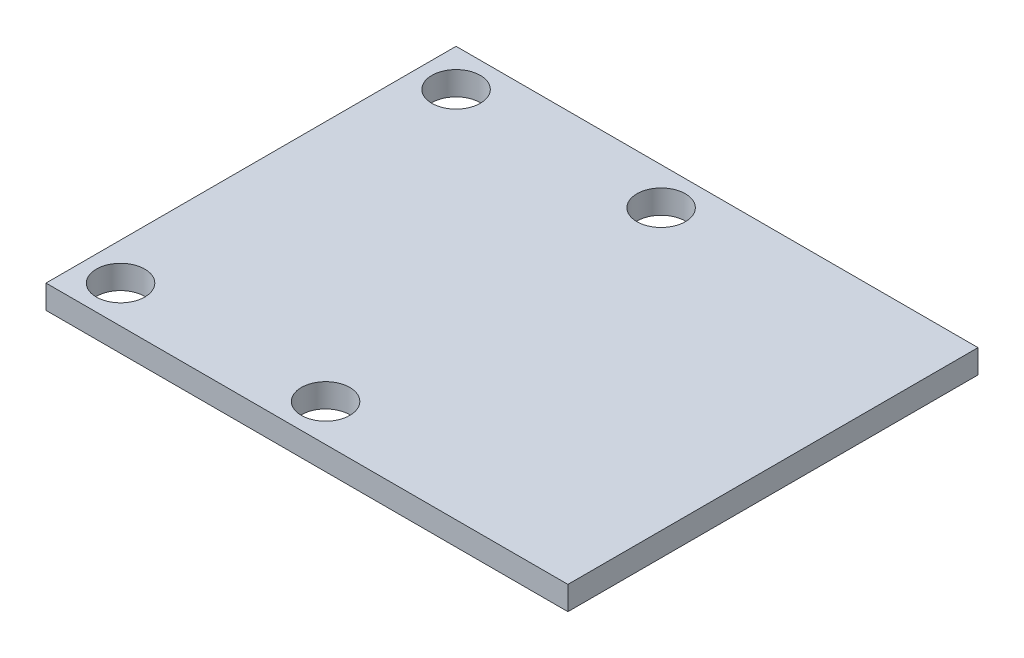
from build123d import *

# Parameters (mm, degrees)
SKETCH1_W            = 28
SKETCH1_H            = 22
BOSS_EXTRUDE1_DEPTH  = 1.27
SKETCH2_R            = 1.2999974
CUT_EXTRUDE2_DEPTH   = 2.27
LPATTERN1_COUNT      = 2
LPATTERN1_PITCH      = 11
LPATTERN1_COUNT_DIR2 = 2
LPATTERN1_PITCH_DIR2 = 18


with BuildPart() as part:
    # Sketch1 → Boss-Extrude1 (new body)
    with BuildSketch(Plane(origin=(0, 0, 0), x_dir=(1, 0, 0), z_dir=(0, 1, 0))):
        Rectangle(SKETCH1_W, SKETCH1_H)
    extrude(amount=BOSS_EXTRUDE1_DEPTH)

    # Sketch2 → Cut-Extrude2 (cut, through all)
    with BuildSketch(Plane(origin=(0, 0, 0), x_dir=(1, 0, 0), z_dir=(0, 1, 0))):
        with Locations((-12, 9)):
            Circle(SKETCH2_R)
    cut_extrude2 = extrude(amount=CUT_EXTRUDE2_DEPTH, mode=Mode.SUBTRACT)

    # LPattern1: Cut-Extrude2 2 × 2
    with Locations(*[(i * LPATTERN1_PITCH, 0, j * LPATTERN1_PITCH_DIR2) for i in range(LPATTERN1_COUNT) for j in range(LPATTERN1_COUNT_DIR2) if (i, j) != (0, 0)]):
        add(cut_extrude2, mode=Mode.SUBTRACT)


solid = part.part
